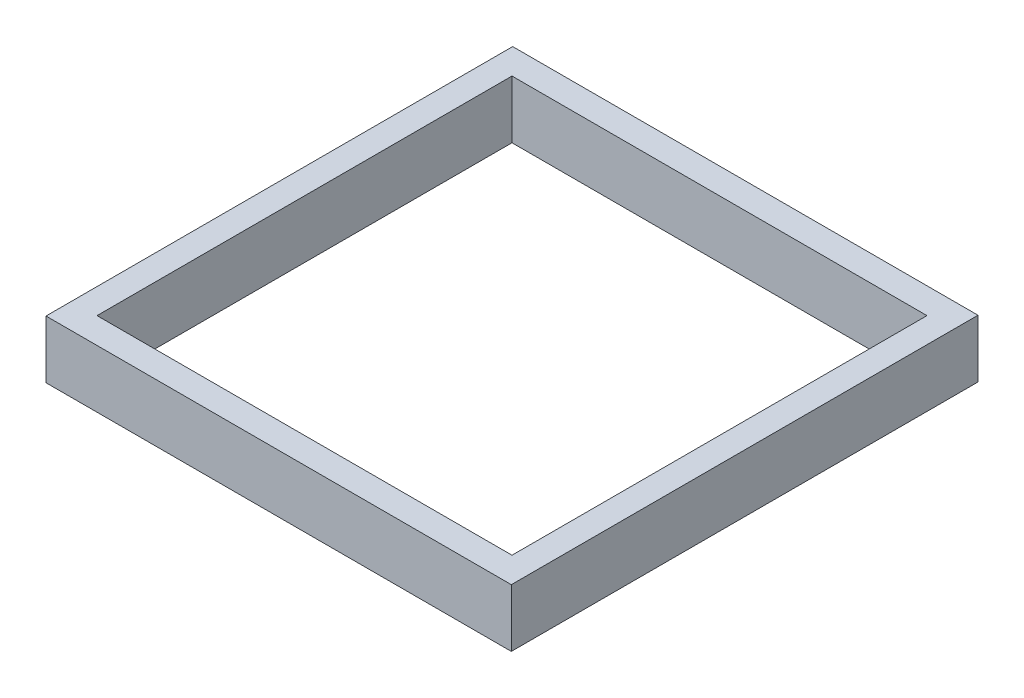
from build123d import *

# Parameters (mm, degrees)
SKETCH1_W             = 37
SKETCH1_H             = 85
BOSS_EXTRUDE1_DEPTH   = 686
BOSS_EXTRUDE1_2_DEPTH = 686
SKETCH2_W             = 38
SKETCH2_H             = 85
BOSS_EXTRUDE2_DEPTH   = 610


with BuildPart() as part:
    # Sketch1 → Boss-Extrude1 (new body)
    with BuildSketch(Plane.XY):
        with Locations((18.5, 42.5)):
            Rectangle(SKETCH1_W, SKETCH1_H)
    extrude(amount=BOSS_EXTRUDE1_DEPTH)



with BuildPart() as body_2:
    # Sketch1 → Boss-Extrude1 2 (new body)
    with BuildSketch(Plane.XY):
        with Locations((-628.5, 42.5)):
            Rectangle(SKETCH1_W, SKETCH1_H)
    extrude(amount=BOSS_EXTRUDE1_2_DEPTH)


with BuildPart() as part_1:
    add(part.part)

    add(body_2.part)  # Boss-Extrude2 merges body 2
    # Sketch2 → Boss-Extrude2 (add)
    with BuildSketch(Plane(origin=(-610, 0, 0), x_dir=(0, 0, -1), z_dir=(1, 0, 0))):
        with Locations((-667, 42.5)):
            Rectangle(SKETCH2_W, SKETCH2_H)
        with Locations((-19, 42.5)):
            Rectangle(SKETCH2_W, SKETCH2_H)
    extrude(amount=BOSS_EXTRUDE2_DEPTH)


solid = part_1.part
